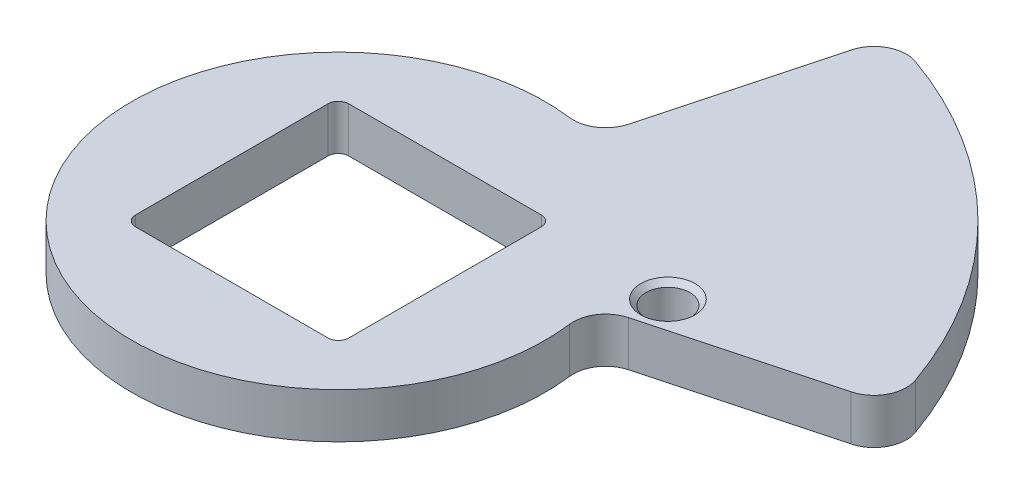
from build123d import *

# Parameters (mm, degrees)
SKETCH3_R           = 2.159
BOSS_EXTRUDE1_DEPTH = 4.445
CHAMFER1_SIZE       = 0.508


with BuildPart() as part:
    # Sketch3 → Boss-Extrude1 (new body)
    with BuildSketch(Plane(origin=(0, 0, 0), x_dir=(1, 0, 0), z_dir=(0, 1, 0))):
        with BuildLine():
            Line((10.651103406, 39.750459069), (6.025173957, 22.486255331))
            ThreePointArc((6.025173957, 22.486255331), (4.728428182, 20.672198197), (2.558581153, 20.158275285))
            ThreePointArc((2.558581153, 20.158275285), (-14.368409794, -14.368409794), (20.158275285, 2.558581153))
            ThreePointArc((20.158275285, 2.558581153), (20.672198197, 4.728428182), (22.486255331, 6.025173957))
            Line((22.486255331, 6.025173957), (39.750459069, 10.651103406))
            ThreePointArc((39.750459069, 10.651103406), (41.737404706, 12.237427719), (41.923224647, 14.773142359))
            ThreePointArc((41.923224647, 14.773142359), (31.430896424, 31.430896424), (14.773142359, 41.923224647))
            ThreePointArc((14.773142359, 41.923224647), (12.237427719, 41.737404706), (10.651103406, 39.750459069))
        make_face()
        with Locations((22.86, 9.525)):
            Circle(SKETCH3_R, mode=Mode.SUBTRACT)
        with BuildLine():
            Line((-9.4615, -10.4775), (9.4615, -10.4775))
            ThreePointArc((9.4615, -10.4775), (10.17992049, -10.17992049), (10.4775, -9.4615))
            Line((10.4775, -9.4615), (10.4775, 9.4615))
            ThreePointArc((10.4775, 9.4615), (10.17992049, 10.17992049), (9.4615, 10.4775))
            Line((9.4615, 10.4775), (-9.4615, 10.4775))
            ThreePointArc((-9.4615, 10.4775), (-10.17992049, 10.17992049), (-10.4775, 9.4615))
            Line((-10.4775, 9.4615), (-10.4775, -9.4615))
            ThreePointArc((-10.4775, -9.4615), (-10.17992049, -10.17992049), (-9.4615, -10.4775))
        make_face(mode=Mode.SUBTRACT)
    extrude(amount=BOSS_EXTRUDE1_DEPTH)

    # Chamfer1
    chamfer1_edges = [part.edges().sort_by_distance(p)[0] for p in [
        (20.701, 0, -9.525),
        (20.701, 4.445, -9.525),
    ]]
    chamfer(chamfer1_edges, length=CHAMFER1_SIZE)


solid = part.part
